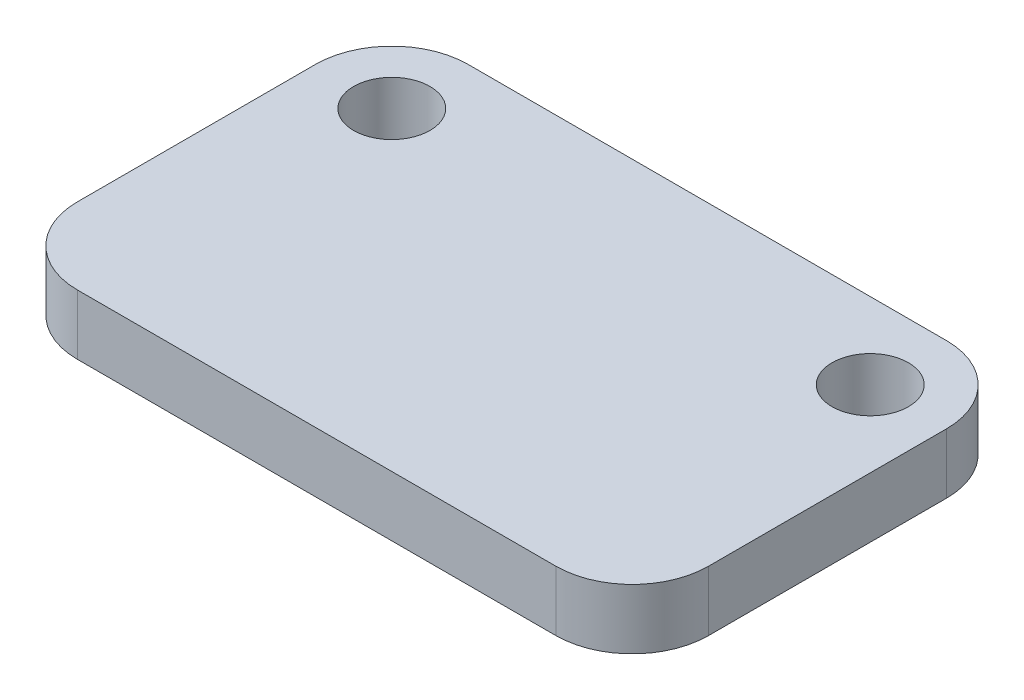
from build123d import *

# Parameters (mm, degrees)
SKETCH1_W           = 21
SKETCH1_H           = 13
BOSS_EXTRUDE1_DEPTH = 2
SKETCH2_R           = 1.27
CUT_EXTRUDE1_DEPTH  = 3
FILLET1_R           = 2.54


with BuildPart() as part:
    # Sketch1 → Boss-Extrude1 (new body)
    with BuildSketch(Plane(origin=(0, 0, 0), x_dir=(1, 0, 0), z_dir=(0, 1, 0))):
        with Locations((10.5, 6.5)):
            Rectangle(SKETCH1_W, SKETCH1_H)
    extrude(amount=BOSS_EXTRUDE1_DEPTH)

    # Sketch2 → Cut-Extrude1 (cut, through all)
    with BuildSketch(Plane(origin=(0, 2, 0), x_dir=(1, 0, 0), z_dir=(0, 1, 0))):
        with Locations((2.54, 10.46)):
            Circle(SKETCH2_R)
        with Locations((18.46, 10.46)):
            Circle(SKETCH2_R)
    extrude(amount=-CUT_EXTRUDE1_DEPTH, mode=Mode.SUBTRACT)

    # Fillet1
    fillet1_edges = [part.edges().sort_by_distance(p)[0] for p in [
        (0, 1, -13),
        (21, 1, -13),
        (21, 1, 0),
        (0, 1, 0),
    ]]
    fillet(fillet1_edges, radius=FILLET1_R)


solid = part.part
